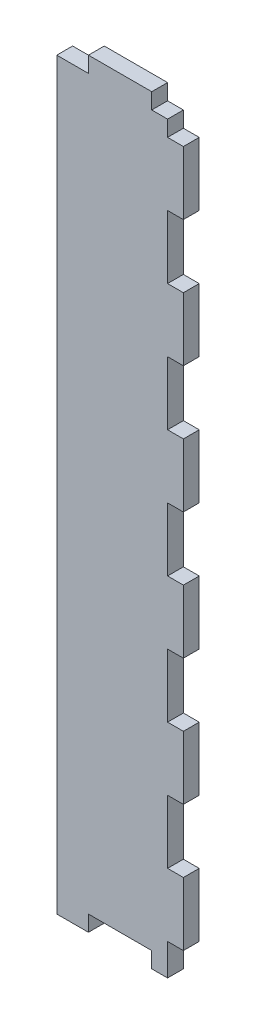
from build123d import *

# Parameters (mm, degrees)
SKETCH1_W          = 25.4
SKETCH1_H          = 152.4
EXTRUDE1_DEPTH     = 3.175
SKETCH3_W          = 3.175
SKETCH3_H          = 6.35
CUT_EXTRUDE1_DEPTH = 3.175
LPATTERN1_COUNT    = 2
LPATTERN1_PITCH    = 146.05
SKETCH4_W          = 3.175
SKETCH4_H          = 12.7
CUT_EXTRUDE2_DEPTH = 3.175
LPATTERN2_COUNT    = 5
LPATTERN2_PITCH    = 25.4
SKETCH5_W          = 12.7
SKETCH5_H          = 3.175
CUT_EXTRUDE3_DEPTH = 3.175
SKETCH6_W          = 6.35
SKETCH6_H          = 3.175
CUT_EXTRUDE4_DEPTH = 3.175
LPATTERN3_COUNT    = 2
LPATTERN3_PITCH    = 19.05


with BuildPart() as part:
    # Sketch1 → Extrude1 (new body)
    with BuildSketch(Plane.XY):
        with Locations((12.7, 76.2)):
            Rectangle(SKETCH1_W, SKETCH1_H)
    extrude(amount=EXTRUDE1_DEPTH)

    # Sketch3 → Cut-Extrude1 (cut)
    with BuildSketch(Plane.XY.offset(3.175)):
        with Locations((23.8125, 149.225)):
            Rectangle(SKETCH3_W, SKETCH3_H)
    cut_extrude1 = extrude(amount=-CUT_EXTRUDE1_DEPTH, mode=Mode.SUBTRACT)

    # LPattern1: Cut-Extrude1 ×2
    with Locations(*[(0, -i * LPATTERN1_PITCH, 0) for i in range(1, LPATTERN1_COUNT)]):
        add(cut_extrude1, mode=Mode.SUBTRACT)

    # Sketch4 → Cut-Extrude2 (cut)
    with BuildSketch(Plane.XY.offset(3.175)):
        with Locations((23.8125, 127)):
            Rectangle(SKETCH4_W, SKETCH4_H)
    cut_extrude2 = extrude(amount=-CUT_EXTRUDE2_DEPTH, mode=Mode.SUBTRACT)

    # LPattern2: Cut-Extrude2 ×5
    with Locations(*[(0, -i * LPATTERN2_PITCH, 0) for i in range(1, LPATTERN2_COUNT)]):
        add(cut_extrude2, mode=Mode.SUBTRACT)

    # Sketch5 → Cut-Extrude3 (cut)
    with BuildSketch(Plane.XY.offset(3.175)):
        with Locations((12.7, 1.5875)):
            Rectangle(SKETCH5_W, SKETCH5_H)
    extrude(amount=-CUT_EXTRUDE3_DEPTH, mode=Mode.SUBTRACT)

    # Sketch6 → Cut-Extrude4 (cut)
    with BuildSketch(Plane.XY.offset(3.175)):
        with Locations((3.175, 150.8125)):
            Rectangle(SKETCH6_W, SKETCH6_H)
    cut_extrude4 = extrude(amount=-CUT_EXTRUDE4_DEPTH, mode=Mode.SUBTRACT)

    # LPattern3: Cut-Extrude4 ×2
    with Locations(*[(i * LPATTERN3_PITCH, 0, 0) for i in range(1, LPATTERN3_COUNT)]):
        add(cut_extrude4, mode=Mode.SUBTRACT)


solid = part.part
